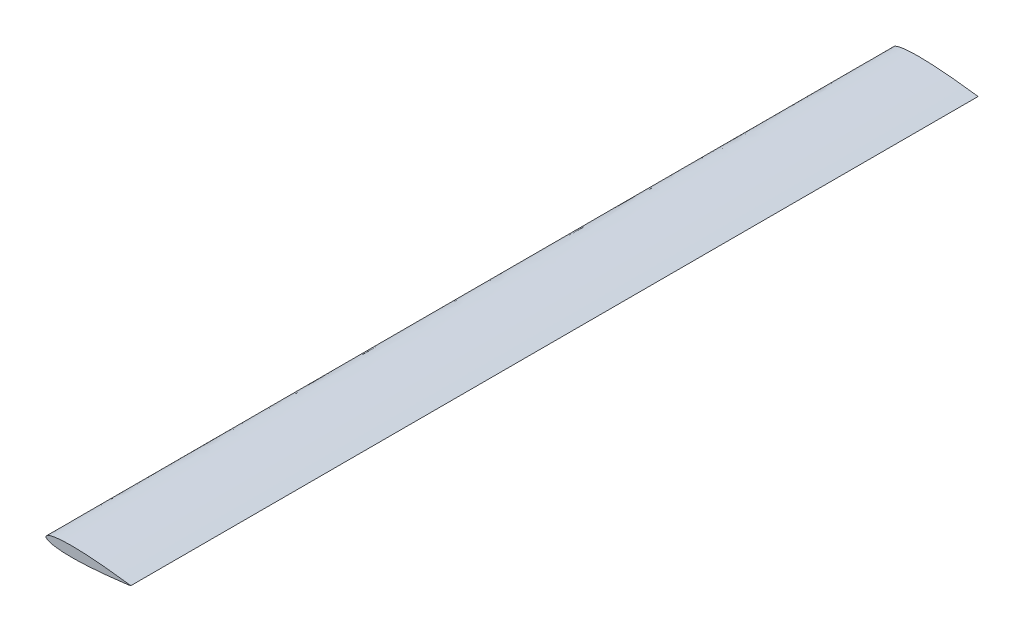
from build123d import *

# Parameters (mm, degrees)
BOSS_EXTRUDE1_DEPTH = 10000


with BuildPart() as part:
    # Sketch1 → Boss-Extrude1 (new body)
    with BuildSketch(Plane.XY):
        with BuildLine():
            add(Edge.make_bspline(
                [(0, 0), (-0.000792795, -1.437209018), (0.409444502, -4.385724699), (2.254347139, -8.66028941), (5.270744478, -12.774951894), (9.421982579, -16.747543387), (14.69461507, -20.592001803), (21.080959613, -24.311993341), (28.571669054, -27.903290237), (37.153463197, -31.357753827), (46.809318667, -34.665106541), (57.51862853, -37.814274542), (69.257826192, -40.793402562), (82.000266589, -43.591684337), (95.716955506, -46.197637409), (110.376185726, -48.601790332), (125.944126705, -50.794291034), (142.384569592, -52.767746768), (159.659307758, -54.515119664), (177.728060471, -56.03155197), (196.548725498, -57.313535787), (216.077457602, -58.358911956), (236.268658255, -59.167886481), (257.07518412, -59.741924849), (278.448476324, -60.084074332), (300.33866593, -60.199421494), (322.694622735, -60.094113531), (345.464143189, -59.775814657), (368.594056669, -59.25346049), (392.030398993, -58.537193193), (415.718425853, -57.637633067), (439.602801495, -56.566490888), (463.627758769, -55.336043114), (487.737220494, -53.958788276), (511.874883186, -52.447613888), (535.984371375, -50.815451756), (560.009401701, -49.075190085), (583.893850791, -47.239941855), (607.581947997, -45.322045013), (631.018326919, -43.334082826), (654.148334194, -41.288152213), (676.917878389, -39.196061385), (699.273833105, -37.069591854), (721.163907941, -34.91959869), (742.537076407, -32.757283856), (763.34332605, -30.593190353), (783.534112501, -28.437988982), (803.062234714, -26.302192454), (821.882065187, -24.195393603), (839.949720905, -22.128326339), (857.222966016, -20.110626062), (873.661453341, -18.152230862), (889.226740486, -16.262812614), (903.882537267, -14.452304232), (917.594569234, -12.729842107), (930.330846083, -11.105129789), (942.061526717, -9.586394729), (952.7593797, -8.183397804), (962.399093374, -6.902391124), (970.959106117, -5.75556351), (978.416539656, -4.737047827), (984.762543682, -3.89107356), (989.957865657, -3.115475002), (994.055890002, -2.703086417), (996.887787519, -1.957199043), (999.511557869, -2.452141014), (1000.48876725, 0.770740833), (998.637324835, 0.784296205), (996.976919866, 1.129601952), (994.01790911, 1.480959843), (989.976743035, 2.073172909), (984.760381509, 2.78643867), (978.423191435, 3.663896003), (970.964194549, 4.682272598), (962.406338582, 5.841298178), (952.767760232, 7.132056909), (942.071550495, 8.547131594), (930.342525187, 10.078722518), (917.60805683, 11.717510815), (903.897931021, 13.455091881), (889.244141323, 15.281770344), (873.680947922, 17.188359061), (857.244631249, 19.164888905), (839.973622645, 21.201644479), (821.908258405, 23.28864351), (803.090763694, 25.416203914), (783.565009667, 27.573543402), (763.376613213, 29.751018798), (742.572763753, 31.938065328), (721.201993852, 34.123958637), (699.314304302, 36.298100557), (676.960709203, 38.449232838), (654.193486949, 40.566442726), (631.065750909, 42.637890104), (607.631579454, 44.651707095), (583.945612569, 46.59573649), (560.063202739, 48.457333947), (536.040106965, 50.224099997), (511.93243412, 51.882859752), (487.796453309, 53.42066292), (463.688525702, 54.824515507), (439.664940532, 56.08146789), (415.781761155, 57.178959681), (392.094741144, 58.104652901), (368.659203299, 58.846775736), (345.529880179, 59.394647492), (322.760724743, 59.73806648), (300.404897723, 59.868038423), (278.514594183, 59.776841523), (257.140937513, 59.458272177), (236.333791006, 58.907188806), (216.141710145, 58.120490567), (196.611836623, 57.096659965), (177.78976871, 55.835440689), (159.719354, 54.338943526), (142.442698571, 52.610629921), (126.000088489, 50.655313186), (110.429738124, 48.479989035), (95.767864461, 46.092010264), (82.048308893, 43.501191615), (69.302789066, 40.716969547), (57.560311848, 37.750794524), (46.847534205, 34.613443407), (37.188035799, 31.316745457), (28.602435767, 27.871751771), (21.107768812, 24.288721131), (14.717324102, 20.575777545), (9.440453449, 16.737138462), (5.284835143, 12.769129209), (2.263900168, 8.657797048), (0.414282772, 4.385270313), (0.000792795, 1.437209018), (0, 0)],
                knots=[0, 0, 0, 0, 0.002106625, 0.004321528, 0.006774253, 0.009558771, 0.012736805, 0.016346435, 0.020410033, 0.024939514, 0.029939567, 0.035409924, 0.041346401, 0.047741949, 0.054587234, 0.06187083, 0.069579668, 0.07769917, 0.08621339, 0.095105076, 0.104355887, 0.113946424, 0.123856213, 0.134063797, 0.144546895, 0.155282409, 0.166246428, 0.177414278, 0.188760778, 0.2002601, 0.211885926, 0.223611509, 0.235409732, 0.247253274, 0.259114618, 0.27096602, 0.282779814, 0.294528421, 0.306184125, 0.317719709, 0.329108028, 0.340322353, 0.351336232, 0.362123847, 0.372659751, 0.382919228, 0.392877986, 0.402512657, 0.411800467, 0.420719532, 0.429248811, 0.437368079, 0.445058129, 0.452300715, 0.459078673, 0.465375853, 0.471177199, 0.476468953, 0.481238379, 0.485474106, 0.489165923, 0.492304968, 0.494883646, 0.496895826, 0.498336554, 0.49920239, 0.500508759, 0.50079761, 0.501663446, 0.503104174, 0.505116354, 0.507695032, 0.510834077, 0.514525894, 0.518761621, 0.523531047, 0.528822801, 0.534624147, 0.540921327, 0.547699285, 0.554941871, 0.562631921, 0.570751189, 0.579280468, 0.588199533, 0.597487343, 0.607122014, 0.617080772, 0.627340249, 0.637876153, 0.648663768, 0.659677647, 0.670891972, 0.682280291, 0.693815875, 0.705471579, 0.717220186, 0.72903398, 0.740885382, 0.752746726, 0.764590268, 0.776388491, 0.788114074, 0.7997399, 0.811239222, 0.822585722, 0.833753572, 0.844717591, 0.855453105, 0.865936203, 0.876143787, 0.886053576, 0.895644113, 0.904894924, 0.91378661, 0.92230083, 0.930420332, 0.93812917, 0.945412766, 0.952258051, 0.958653599, 0.964590076, 0.970060433, 0.975060486, 0.979589967, 0.983653565, 0.987263195, 0.990441229, 0.993225747, 0.995678472, 0.997893375, 1, 1, 1, 1], degree=3))
        make_face()
    extrude(amount=BOSS_EXTRUDE1_DEPTH)


solid = part.part
